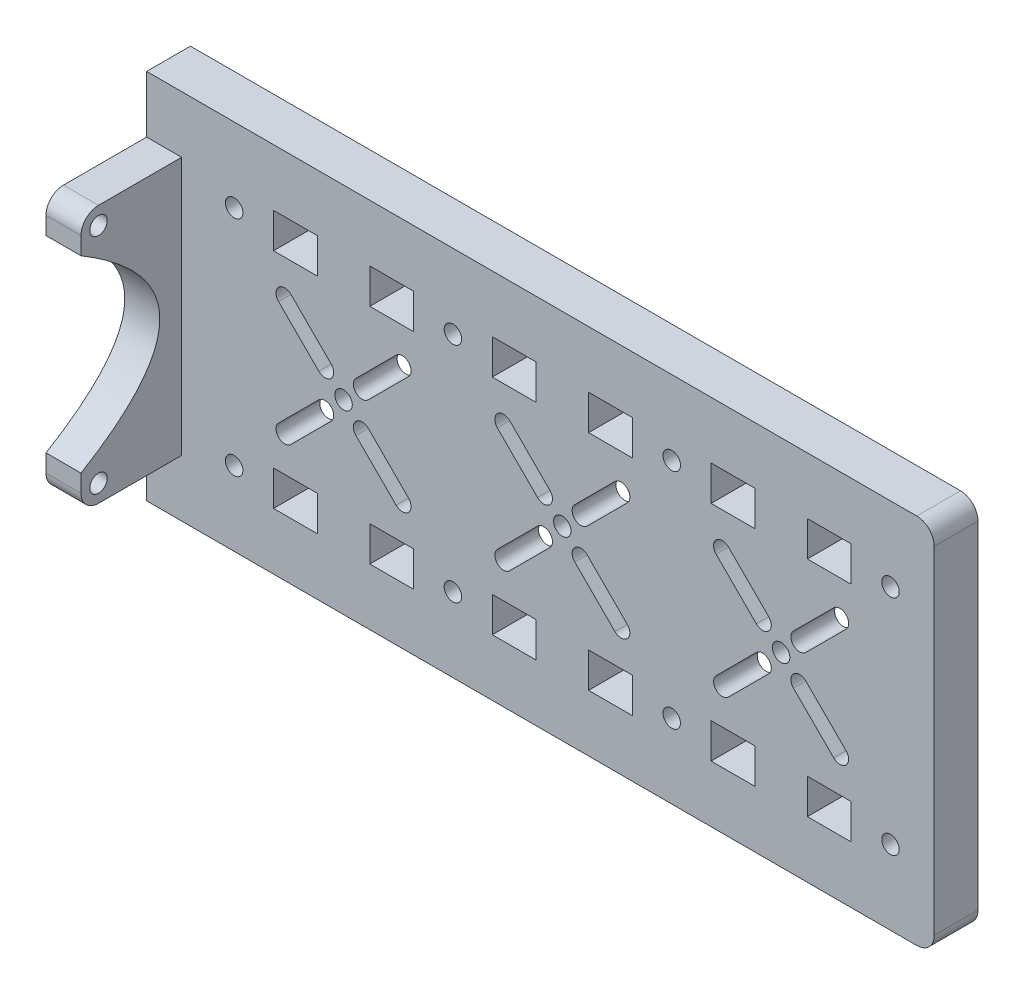
from build123d import *

# Parameters (mm, degrees)
IZIM1_W                     = 180
IZIM1_H                     = 85
Y_KSEKLIK_EKSTR_ZYON1_DEPTH = 10
IZIM2_R                     = 2
IZIM2_W                     = 10
IZIM2_H                     = 8
KES_EKSTR_ZYON1_DEPTH       = 10
IZIM3_R                     = 5
IZIM3_R_2                   = 4.5
KES_EKSTR_ZYON2_DEPTH       = 5
SKETCH1_R                   = 2
BOSS_EXTRUDE1_DEPTH         = 8
FILLET1_R                   = 4


with BuildPart() as part:
    # Çizim1 → Yükseklik-Ekstrüzyon1 (new body)
    with BuildSketch(Plane.XY):
        Rectangle(IZIM1_W, IZIM1_H)
    extrude(amount=Y_KSEKLIK_EKSTR_ZYON1_DEPTH)

    # Çizim2 → Kes-Ekstrüzyon1 (cut)
    with BuildSketch(Plane.XY.offset(10)):
        with Locations((-70, -25.5)):
            Circle(IZIM2_R)
        with Locations((-45, 0)):
            Circle(IZIM2_R)
        with Locations((-70, 25.5)):
            Circle(IZIM2_R)
        with Locations((80, 25.5)):
            Circle(IZIM2_R)
        with Locations((80, -25.5)):
            Circle(IZIM2_R)
        with Locations((-20, 25.5)):
            Circle(IZIM2_R)
        with Locations((5, 0)):
            Circle(IZIM2_R)
        with Locations((-20, -25.5)):
            Circle(IZIM2_R)
        with Locations((30, 25.5)):
            Circle(IZIM2_R)
        with Locations((55, 0)):
            Circle(IZIM2_R)
        with Locations((30, -25.5)):
            Circle(IZIM2_R)
        with Locations((-56, -25.5)):
            Rectangle(IZIM2_W, IZIM2_H)
        with BuildLine():
            Line((-59.849242405, -12.02081528), (-50.656854249, -2.828427125))
            ThreePointArc((-50.656854249, -2.828427125), (-47.828427125, -2.828427125), (-47.828427125, -5.656854249))
            Line((-47.828427125, -5.656854249), (-57.02081528, -14.849242405))
            ThreePointArc((-57.02081528, -14.849242405), (-59.849242405, -14.849242405), (-59.849242405, -12.02081528))
        make_face()
        with Locations((-34, -25.5)):
            Rectangle(IZIM2_W, IZIM2_H)
        with BuildLine():
            Line((-30.150757595, -12.02081528), (-39.343145751, -2.828427125))
            ThreePointArc((-39.343145751, -2.828427125), (-42.171572875, -2.828427125), (-42.171572875, -5.656854249))
            Line((-42.171572875, -5.656854249), (-32.97918472, -14.849242405))
            ThreePointArc((-32.97918472, -14.849242405), (-30.150757595, -14.849242405), (-30.150757595, -12.02081528))
        make_face()
        with BuildLine():
            Line((-59.849242405, 12.02081528), (-50.656854249, 2.828427125))
            ThreePointArc((-50.656854249, 2.828427125), (-47.828427125, 2.828427125), (-47.828427125, 5.656854249))
            Line((-47.828427125, 5.656854249), (-57.02081528, 14.849242405))
            ThreePointArc((-57.02081528, 14.849242405), (-59.849242405, 14.849242405), (-59.849242405, 12.02081528))
        make_face()
        with BuildLine():
            Line((-30.150757595, 12.02081528), (-39.343145751, 2.828427125))
            ThreePointArc((-39.343145751, 2.828427125), (-42.171572875, 2.828427125), (-42.171572875, 5.656854249))
            Line((-42.171572875, 5.656854249), (-32.97918472, 14.849242405))
            ThreePointArc((-32.97918472, 14.849242405), (-30.150757595, 14.849242405), (-30.150757595, 12.02081528))
        make_face()
        with Locations((-34, 25.5)):
            Rectangle(IZIM2_W, IZIM2_H)
        with Locations((-56, 25.5)):
            Rectangle(IZIM2_W, IZIM2_H)
        with Locations((-6, 25.5)):
            Rectangle(IZIM2_W, IZIM2_H)
        with Locations((16, 25.5)):
            Rectangle(IZIM2_W, IZIM2_H)
        with BuildLine():
            Line((-9.849242405, 12.02081528), (-0.656854249, 2.828427125))
            ThreePointArc((-0.656854249, 2.828427125), (2.171572875, 2.828427125), (2.171572875, 5.656854249))
            Line((2.171572875, 5.656854249), (-7.02081528, 14.849242405))
            ThreePointArc((-7.02081528, 14.849242405), (-9.849242405, 14.849242405), (-9.849242405, 12.02081528))
        make_face()
        with BuildLine():
            Line((19.849242405, 12.02081528), (10.656854249, 2.828427125))
            ThreePointArc((10.656854249, 2.828427125), (7.828427125, 2.828427125), (7.828427125, 5.656854249))
            Line((7.828427125, 5.656854249), (17.02081528, 14.849242405))
            ThreePointArc((17.02081528, 14.849242405), (19.849242405, 14.849242405), (19.849242405, 12.02081528))
        make_face()
        with BuildLine():
            Line((17.02081528, -14.849242405), (7.828427125, -5.656854249))
            ThreePointArc((7.828427125, -5.656854249), (7.828427125, -2.828427125), (10.656854249, -2.828427125))
            Line((10.656854249, -2.828427125), (19.849242405, -12.02081528))
            ThreePointArc((19.849242405, -12.02081528), (19.849242405, -14.849242405), (17.02081528, -14.849242405))
        make_face()
        with BuildLine():
            Line((-9.849242405, -12.02081528), (-0.656854249, -2.828427125))
            ThreePointArc((-0.656854249, -2.828427125), (2.171572875, -2.828427125), (2.171572875, -5.656854249))
            Line((2.171572875, -5.656854249), (-7.02081528, -14.849242405))
            ThreePointArc((-7.02081528, -14.849242405), (-9.849242405, -14.849242405), (-9.849242405, -12.02081528))
        make_face()
        with Locations((-6, -25.5)):
            Rectangle(IZIM2_W, IZIM2_H)
        with Locations((16, -25.5)):
            Rectangle(IZIM2_W, IZIM2_H)
        with Locations((44, 25.5)):
            Rectangle(IZIM2_W, IZIM2_H)
        with Locations((66, 25.5)):
            Rectangle(IZIM2_W, IZIM2_H)
        with BuildLine():
            Line((40.150757595, 12.02081528), (49.343145751, 2.828427125))
            ThreePointArc((49.343145751, 2.828427125), (52.171572875, 2.828427125), (52.171572875, 5.656854249))
            Line((52.171572875, 5.656854249), (42.97918472, 14.849242405))
            ThreePointArc((42.97918472, 14.849242405), (40.150757595, 14.849242405), (40.150757595, 12.02081528))
        make_face()
        with BuildLine():
            Line((69.849242405, 12.02081528), (60.656854249, 2.828427125))
            ThreePointArc((60.656854249, 2.828427125), (57.828427125, 2.828427125), (57.828427125, 5.656854249))
            Line((57.828427125, 5.656854249), (67.02081528, 14.849242405))
            ThreePointArc((67.02081528, 14.849242405), (69.849242405, 14.849242405), (69.849242405, 12.02081528))
        make_face()
        with BuildLine():
            Line((67.02081528, -14.849242405), (57.828427125, -5.656854249))
            ThreePointArc((57.828427125, -5.656854249), (57.828427125, -2.828427125), (60.656854249, -2.828427125))
            Line((60.656854249, -2.828427125), (69.849242405, -12.02081528))
            ThreePointArc((69.849242405, -12.02081528), (69.849242405, -14.849242405), (67.02081528, -14.849242405))
        make_face()
        with BuildLine():
            Line((40.150757595, -12.02081528), (49.343145751, -2.828427125))
            ThreePointArc((49.343145751, -2.828427125), (52.171572875, -2.828427125), (52.171572875, -5.656854249))
            Line((52.171572875, -5.656854249), (42.97918472, -14.849242405))
            ThreePointArc((42.97918472, -14.849242405), (40.150757595, -14.849242405), (40.150757595, -12.02081528))
        make_face()
        with Locations((44, -25.5)):
            Rectangle(IZIM2_W, IZIM2_H)
        with Locations((66, -25.5)):
            Rectangle(IZIM2_W, IZIM2_H)
    extrude(amount=-KES_EKSTR_ZYON1_DEPTH, mode=Mode.SUBTRACT)

    # Çizim3 → Kes-Ekstrüzyon2 (cut)
    with BuildSketch(Plane(origin=(0, 0, 0), x_dir=(-1, 0, 0), z_dir=(0, 0, -1))):
        with Locations((70, 25.5)):
            Circle(IZIM3_R)
        with Locations((70, -25.5)):
            Circle(IZIM3_R_2)
        with Locations((20, 25.5)):
            Circle(IZIM3_R)
        with Locations((20, -25.5)):
            Circle(IZIM3_R_2)
        with Locations((-30, 25.5)):
            Circle(IZIM3_R)
        with Locations((-30, -25.5)):
            Circle(IZIM3_R_2)
        with Locations((-80, 25.5)):
            Circle(IZIM3_R)
        with Locations((-80, -25.5)):
            Circle(IZIM3_R_2)
    extrude(amount=-KES_EKSTR_ZYON2_DEPTH, mode=Mode.SUBTRACT)

    # Sketch1 → Boss-Extrude1 (add)
    with BuildSketch(Plane.ZY.offset(90)):
        with BuildLine():
            Line((10, -29.5), (33, -29.5))
            Line((33, -29.5), (33, -21.5))
            add(Edge.make_bspline(
                [(33, 21.5), (-3, 0), (33, -21.5)],
                knots=[0, 0, 0, 1, 1, 1], degree=2))
            Line((33, 21.5), (33, 29.5))
            Line((33, 29.5), (10, 29.5))
            Line((10, 29.5), (10, -29.5))
        make_face()
        with Locations((29, -25.5)):
            Circle(SKETCH1_R, mode=Mode.SUBTRACT)
        with Locations((29, 25.5)):
            Circle(SKETCH1_R, mode=Mode.SUBTRACT)
    extrude(amount=-BOSS_EXTRUDE1_DEPTH)

    # Fillet1
    fillet1_edges = [part.edges().sort_by_distance(p)[0] for p in [
        (-86, 29.5, 33),
        (-86, -29.5, 33),
        (90, 42.5, 5),
        (90, -42.5, 5),
    ]]
    fillet(fillet1_edges, radius=FILLET1_R)


solid = part.part
